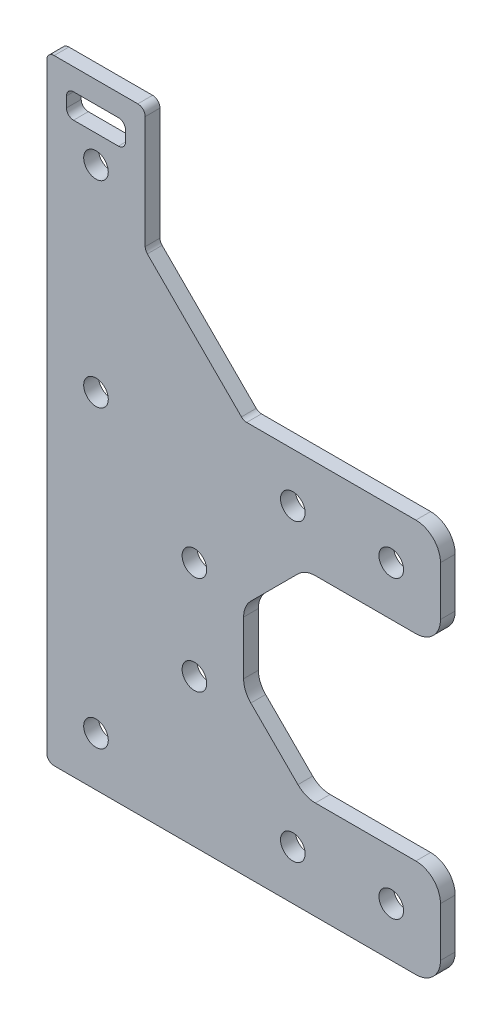
from build123d import *

# Parameters (mm, degrees)
MODEL_R             = 2.5
BOSS_EXTRUDE1_DEPTH = 3


with BuildPart() as part:
    # Model → Boss-Extrude1 (new body)
    with BuildSketch(Plane.XY):
        with BuildLine():
            Line((-36.75, 0), (36.75, 0))
            ThreePointArc((36.75, 0), (40.285533906, 1.464466094), (41.75, 5))
            Line((41.75, 5), (41.75, 15))
            ThreePointArc((41.75, 15), (40.285533906, 18.535533906), (36.75, 20))
            Line((36.75, 20), (16.321067812, 20))
            ThreePointArc((16.321067812, 20), (14.40765065, 20.380602337), (12.785533906, 21.464466094))
            Line((12.785533906, 21.464466094), (3.214466094, 31.035533906))
            ThreePointArc((3.214466094, 31.035533906), (2.130602337, 32.65765065), (1.75, 34.571067812))
            Line((1.75, 34.571067812), (1.75, 45.428932188))
            ThreePointArc((1.75, 45.428932188), (2.130602337, 47.34234935), (3.214466094, 48.964466094))
            Line((3.214466094, 48.964466094), (12.785533906, 58.535533906))
            ThreePointArc((12.785533906, 58.535533906), (14.40765065, 59.619397663), (16.321067812, 60))
            Line((16.321067812, 60), (36.75, 60))
            ThreePointArc((36.75, 60), (40.285533906, 61.464466094), (41.75, 65))
            Line((41.75, 65), (41.75, 75))
            ThreePointArc((41.75, 75), (40.285533906, 78.535533906), (36.75, 80))
            Line((36.75, 80), (2.371320344, 80))
            ThreePointArc((2.371320344, 80), (1.797295195, 80.114180701), (1.310660172, 80.439339828))
            Line((1.310660172, 80.439339828), (-17.810660172, 99.560660172))
            ThreePointArc((-17.810660172, 99.560660172), (-18.135819299, 100.047295195), (-18.25, 100.621320344))
            Line((-18.25, 100.621320344), (-18.25, 123.5))
            ThreePointArc((-18.25, 123.5), (-18.689339828, 124.560660172), (-19.75, 125))
            Line((-19.75, 125), (-36.75, 125))
            ThreePointArc((-36.75, 125), (-37.810660172, 124.560660172), (-38.25, 123.5))
            Line((-38.25, 123.5), (-38.25, 1.5))
            ThreePointArc((-38.25, 1.5), (-37.810660172, 0.439339828), (-36.75, 0))
        make_face()
        with Locations((-28.25, 70)):
            Circle(MODEL_R, mode=Mode.SUBTRACT)
        with Locations((-8.25, 30)):
            Circle(MODEL_R, mode=Mode.SUBTRACT)
        with Locations((-8.25, 50)):
            Circle(MODEL_R, mode=Mode.SUBTRACT)
        with Locations((11.75, 70)):
            Circle(MODEL_R, mode=Mode.SUBTRACT)
        with Locations((31.75, 70)):
            Circle(MODEL_R, mode=Mode.SUBTRACT)
        with Locations((31.75, 10)):
            Circle(MODEL_R, mode=Mode.SUBTRACT)
        with Locations((11.75, 10)):
            Circle(MODEL_R, mode=Mode.SUBTRACT)
        with Locations((-28.25, 10)):
            Circle(MODEL_R, mode=Mode.SUBTRACT)
        with Locations((-28.25, 110)):
            Circle(MODEL_R, mode=Mode.SUBTRACT)
        with BuildLine():
            Line((-34.25, 119.15), (-34.25, 117.03))
            ThreePointArc((-34.25, 117.03), (-33.828233765, 116.011766235), (-32.81, 115.59))
            Line((-32.81, 115.59), (-23.69, 115.59))
            ThreePointArc((-23.69, 115.59), (-22.671766235, 116.011766235), (-22.25, 117.03))
            Line((-22.25, 117.03), (-22.25, 119.15))
            ThreePointArc((-22.25, 119.15), (-22.671766235, 120.168233765), (-23.69, 120.59))
            Line((-23.69, 120.59), (-32.81, 120.59))
            ThreePointArc((-32.81, 120.59), (-33.828233765, 120.168233765), (-34.25, 119.15))
        make_face(mode=Mode.SUBTRACT)
    extrude(amount=BOSS_EXTRUDE1_DEPTH)


solid = part.part
